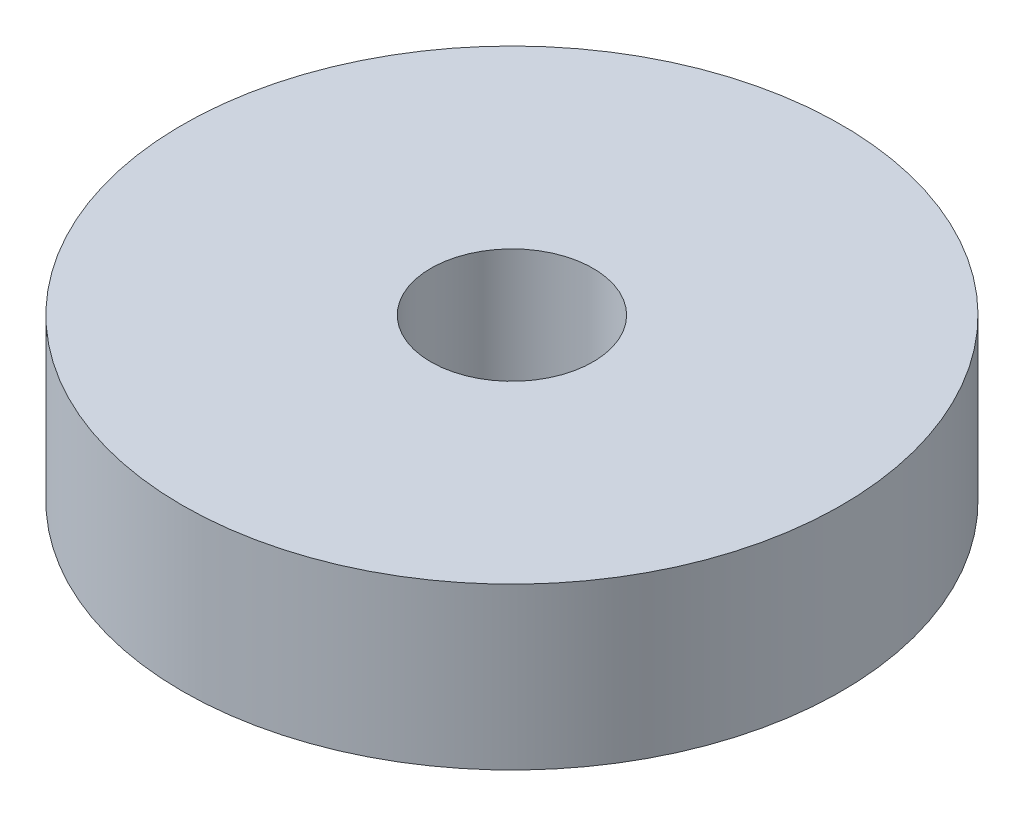
from build123d import *

# Parameters (mm, degrees)
SKETCH1_R           = 6.5
SKETCH1_R_2         = 1.6
BOSS_EXTRUDE1_DEPTH = 1.5875


with BuildPart() as part:
    # Sketch1 → Boss-Extrude1 (new body, symmetric)
    with BuildSketch(Plane(origin=(0, 0, 0), x_dir=(1, 0, 0), z_dir=(0, 1, 0))):
        Circle(SKETCH1_R)
        Circle(SKETCH1_R_2, mode=Mode.SUBTRACT)
    extrude(amount=BOSS_EXTRUDE1_DEPTH, both=True)


solid = part.part
